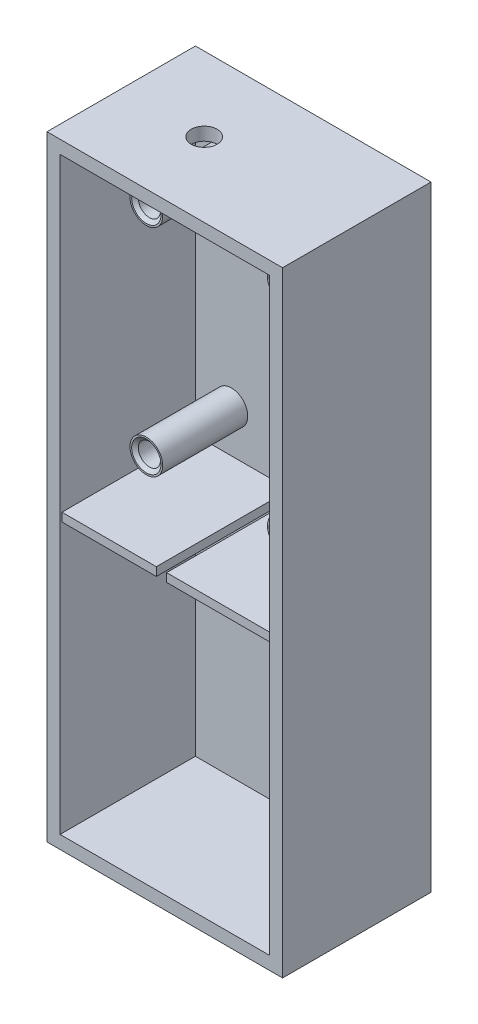
from build123d import *

# Parameters (mm, degrees)
SKETCH1_W                            = 45.72
SKETCH1_H                            = 119.38
BOSS_EXTRUDE1_DEPTH                  = 14.403566373
SHELL3_T                             = -2.54
SKETCH4_R                            = 3.175
BOSS_EXTRUDE2_DEPTH                  = 16.51
F_8_0_199_DIAMETER_HOLE1_D           = 5.0546
F_8_0_199_DIAMETER_HOLE1_DEPTH       = 2.54
SKETCH19_W                           = 40.64
SKETCH19_H                           = 1.642675469
BOSS_EXTRUDE3_DEPTH                  = 25.908
SKETCH23_W                           = 2.002221862
SKETCH23_H                           = 25.908
CUT_EXTRUDE2_DEPTH                   = 15.748
F_4_0_209_DIAMETER_HOLE1_D           = 4.2926
F_4_0_209_DIAMETER_HOLE1_DEPTH       = 13.462
F_4_0_209_DIAMETER_HOLE1_CSINK_D     = 5.6896
F_4_0_209_DIAMETER_HOLE1_CSINK_ANGLE = 100
F_4_0_209_DIAMETER_HOLE1_TIP         = 1.289627147


with BuildPart() as part:
    # Sketch1 → Boss-Extrude1 (new body, symmetric)
    with BuildSketch(Plane.XY):
        Rectangle(SKETCH1_W, SKETCH1_H)
    extrude(amount=BOSS_EXTRUDE1_DEPTH, both=True)

    # Shell3
    shell3_openings = [part.faces().sort_by_distance(p)[0] for p in [
        (0, 0, 14.403566373),
    ]]
    offset(amount=SHELL3_T, openings=shell3_openings, kind=Kind.INTERSECTION)

    # Sketch4 → Boss-Extrude2 (add)
    with BuildSketch(Plane.XY.offset(-11.863566373)):
        with Locations((-13.335, 46.99)):
            Circle(SKETCH4_R)
        with Locations((13.335, 46.99)):
            Circle(SKETCH4_R)
        with Locations((13.335, 5.08)):
            Circle(SKETCH4_R)
        with Locations((-13.335, 5.08)):
            Circle(SKETCH4_R)
    extrude(amount=BOSS_EXTRUDE2_DEPTH)

    # #8 (0.199) Diameter Hole1
    with Locations(Plane(origin=(0, 59.69, 0), x_dir=(1, 0, 0), z_dir=(0, 1, 0))):
        with Locations((-6.761861897, 0), (-42.285600541, -5.559615493)):
            Hole(F_8_0_199_DIAMETER_HOLE1_D / 2, depth=F_8_0_199_DIAMETER_HOLE1_DEPTH)

    # Sketch19 → Boss-Extrude3 (add)
    with BuildSketch(Plane.XY.offset(-11.863566373)):
        with Locations((0, -3.991920643)):
            Rectangle(SKETCH19_W, SKETCH19_H)
    extrude(amount=BOSS_EXTRUDE3_DEPTH)

    # Sketch23 → Cut-Extrude2 (cut)
    with BuildSketch(Plane.XZ.offset(4.813258377)):
        with Locations((-1.001110931, 1.090433627)):
            Rectangle(SKETCH23_W, SKETCH23_H)
    extrude(amount=-CUT_EXTRUDE2_DEPTH, mode=Mode.SUBTRACT)

    # #4 (0.209) Diameter Hole1
    with Locations(Plane.XY.offset(4.646433627)):
        with Locations((-13.335, 5.08), (-13.335, 46.99), (13.335, 5.08), (13.335, 46.99)):
            CounterSinkHole(F_4_0_209_DIAMETER_HOLE1_D / 2, F_4_0_209_DIAMETER_HOLE1_CSINK_D / 2, depth=F_4_0_209_DIAMETER_HOLE1_DEPTH, counter_sink_angle=F_4_0_209_DIAMETER_HOLE1_CSINK_ANGLE)
            with Locations((0, 0, -(F_4_0_209_DIAMETER_HOLE1_DEPTH + F_4_0_209_DIAMETER_HOLE1_TIP / 2))):  # 118° drill point
                Cone(0, F_4_0_209_DIAMETER_HOLE1_D / 2, F_4_0_209_DIAMETER_HOLE1_TIP, mode=Mode.SUBTRACT)


solid = part.part
